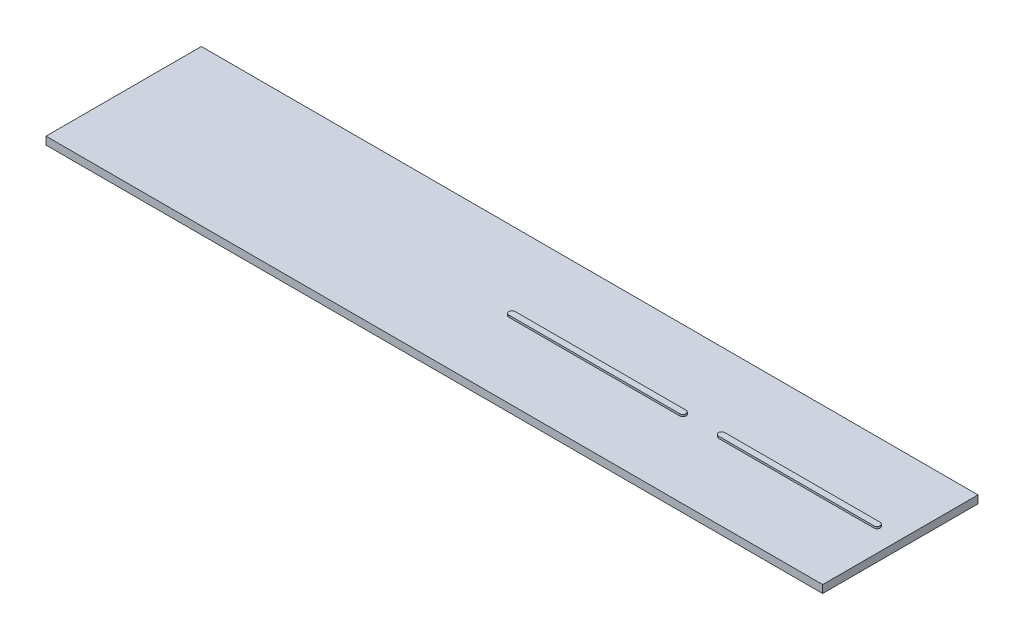
from build123d import *

# Parameters (mm, degrees)
SKETCH1_W           = 100000
SKETCH1_H           = 20000
BOSS_EXTRUDE1_DEPTH = 1000
BOSS_EXTRUDE2_DEPTH = 250


with BuildPart() as part:
    # Sketch1 → Boss-Extrude1 (new body)
    with BuildSketch(Plane(origin=(0, 0, 0), x_dir=(1, 0, 0), z_dir=(0, 1, 0))):
        Rectangle(SKETCH1_W, SKETCH1_H)
    extrude(amount=-BOSS_EXTRUDE1_DEPTH)

    # Sketch2 → Boss-Extrude2 (add)
    with BuildSketch(Plane(origin=(0, 0, 0), x_dir=(1, 0, 0), z_dir=(0, 1, 0))):
        with BuildLine():
            Line((47000, -400), (27000, -400))
            ThreePointArc((27000, -400), (26600, 0), (27000, 400))
            Line((27000, 400), (47000, 400))
            ThreePointArc((47000, 400), (47400, 0), (47000, -400))
        make_face()
        with BuildLine():
            Line((0, 400), (22000, 400))
            ThreePointArc((22000, 400), (22400, 0), (22000, -400))
            Line((22000, -400), (0, -400))
            ThreePointArc((0, -400), (-400, 0), (0, 400))
        make_face()
    extrude(amount=BOSS_EXTRUDE2_DEPTH)


solid = part.part
